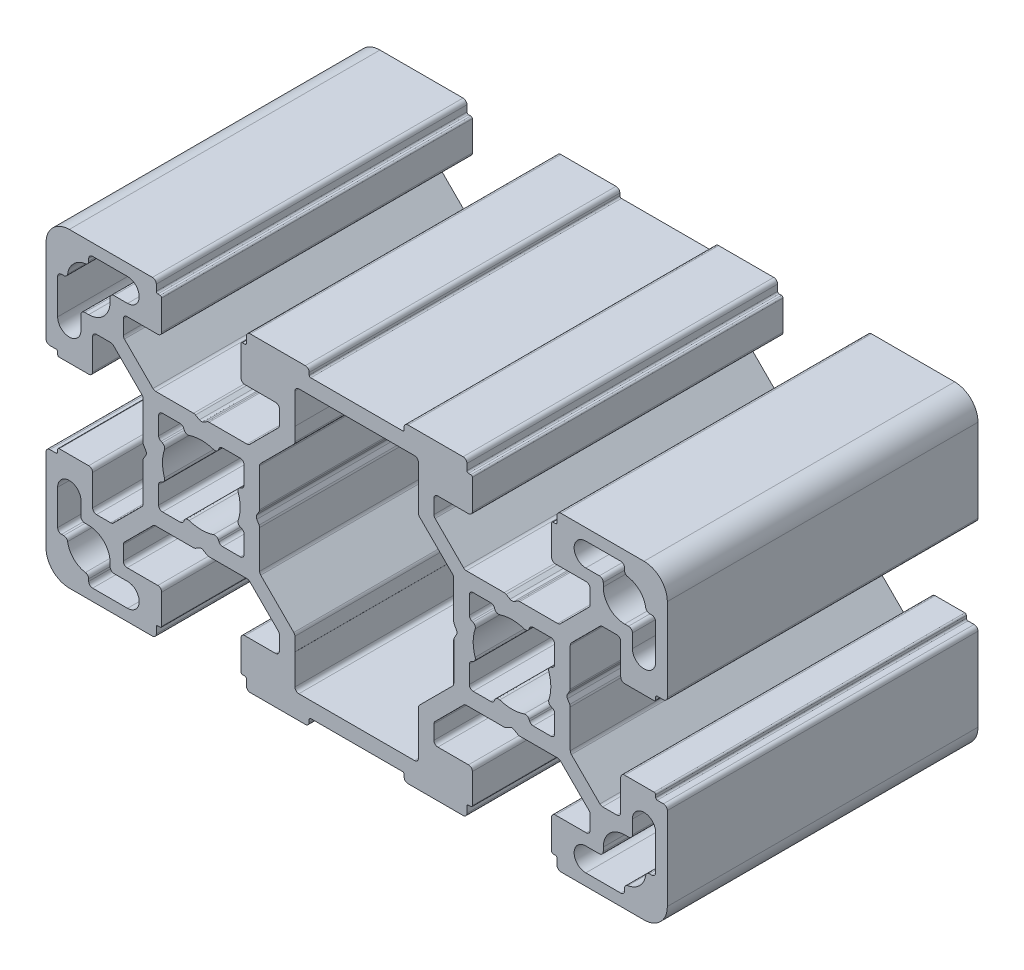
from build123d import *

# Parameters (mm, degrees)
EXTRUDE_1_DEPTH = 40


with BuildPart() as part:
    # Эскиз1 → Бобышка-Вытянуть1 (new body)
    with BuildSketch(Plane.XY):
        with BuildLine():
            Line((0.75, 7.433012702), (0.25, 7.144337567))
            ThreePointArc((0.25, 7.144337567), (0, 7.077350269), (-0.25, 7.144337567))
            Line((-0.25, 7.144337567), (-0.75, 7.433012702))
            ThreePointArc((-0.75, 7.433012702), (-0.870590477, 7.482962913), (-1, 7.5))
            Line((-1, 7.5), (-5.878679656, 7.5))
            ThreePointArc((-5.878679656, 7.5), (-6.070021373, 7.538060234), (-6.232233047, 7.646446609))
            Line((-6.232233047, 7.646446609), (-9.903553391, 11.317766953))
            ThreePointArc((-9.903553391, 11.317766953), (-10.011939766, 11.479978627), (-10.05, 11.671320344))
            Line((-10.05, 11.671320344), (-10.05, 13.5))
            ThreePointArc((-10.05, 13.5), (-9.903553391, 13.853553391), (-9.55, 14))
            Line((-9.55, 14), (-5.6, 14))
            ThreePointArc((-5.6, 14), (-5.246446609, 14.146446609), (-5.1, 14.5))
            Line((-5.1, 14.5), (-5.1, 18.3))
            ThreePointArc((-5.1, 18.3), (-5.158578644, 18.441421356), (-5.3, 18.5))
            Line((-5.3, 18.5), (-5.6, 18.5))
            ThreePointArc((-5.6, 18.5), (-5.741421356, 18.558578644), (-5.8, 18.7))
            Line((-5.8, 18.7), (-5.8, 19.5))
            ThreePointArc((-5.8, 19.5), (-5.946446609, 19.853553391), (-6.3, 20))
            Line((-6.3, 20), (-17, 20))
            ThreePointArc((-17, 20), (-19.121320344, 19.121320344), (-20, 17))
            Line((-20, 17), (-20, 6.3))
            ThreePointArc((-20, 6.3), (-19.853553391, 5.946446609), (-19.5, 5.8))
            Line((-19.5, 5.8), (-18.7, 5.8))
            ThreePointArc((-18.7, 5.8), (-18.558578644, 5.741421356), (-18.5, 5.6))
            Line((-18.5, 5.6), (-18.5, 5.3))
            ThreePointArc((-18.5, 5.3), (-18.441421356, 5.158578644), (-18.3, 5.1))
            Line((-18.3, 5.1), (-14.5, 5.1))
            ThreePointArc((-14.5, 5.1), (-14.146446609, 5.246446609), (-14, 5.6))
            Line((-14, 5.6), (-14, 9.55))
            ThreePointArc((-14, 9.55), (-13.853553391, 9.903553391), (-13.5, 10.05))
            Line((-13.5, 10.05), (-11.671320344, 10.05))
            ThreePointArc((-11.671320344, 10.05), (-11.479978627, 10.011939766), (-11.317766953, 9.903553391))
            Line((-11.317766953, 9.903553391), (-7.646446609, 6.232233047))
            ThreePointArc((-7.646446609, 6.232233047), (-7.538060234, 6.070021373), (-7.5, 5.878679656))
            Line((-7.5, 5.878679656), (-7.5, 1))
            ThreePointArc((-7.5, 1), (-7.482962913, 0.870590477), (-7.433012702, 0.75))
            Line((-7.433012702, 0.75), (-7.144337567, 0.25))
            ThreePointArc((-7.144337567, 0.25), (-7.077350269, 0), (-7.144337567, -0.25))
            Line((-7.144337567, -0.25), (-7.433012702, -0.75))
            ThreePointArc((-7.433012702, -0.75), (-7.482962913, -0.870590477), (-7.5, -1))
            Line((-7.5, -1), (-7.5, -5.878679656))
            ThreePointArc((-7.5, -5.878679656), (-7.538060234, -6.070021373), (-7.646446609, -6.232233047))
            Line((-7.646446609, -6.232233047), (-11.317766953, -9.903553391))
            ThreePointArc((-11.317766953, -9.903553391), (-11.479978627, -10.011939766), (-11.671320344, -10.05))
            Line((-11.671320344, -10.05), (-13.5, -10.05))
            ThreePointArc((-13.5, -10.05), (-13.853553391, -9.903553391), (-14, -9.55))
            Line((-14, -9.55), (-14, -5.6))
            ThreePointArc((-14, -5.6), (-14.146446609, -5.246446609), (-14.5, -5.1))
            Line((-14.5, -5.1), (-18.3, -5.1))
            ThreePointArc((-18.3, -5.1), (-18.441421356, -5.158578644), (-18.5, -5.3))
            Line((-18.5, -5.3), (-18.5, -5.6))
            ThreePointArc((-18.5, -5.6), (-18.558578644, -5.741421356), (-18.7, -5.8))
            Line((-18.7, -5.8), (-19.5, -5.8))
            ThreePointArc((-19.5, -5.8), (-19.853553391, -5.946446609), (-20, -6.3))
            Line((-20, -6.3), (-20, -17))
            ThreePointArc((-20, -17), (-19.121320344, -19.121320344), (-17, -20))
            Line((-17, -20), (-6.3, -20))
            ThreePointArc((-6.3, -20), (-5.946446609, -19.853553391), (-5.8, -19.5))
            Line((-5.8, -19.5), (-5.8, -18.7))
            ThreePointArc((-5.8, -18.7), (-5.741421356, -18.558578644), (-5.6, -18.5))
            Line((-5.6, -18.5), (-5.3, -18.5))
            ThreePointArc((-5.3, -18.5), (-5.158578644, -18.441421356), (-5.1, -18.3))
            Line((-5.1, -18.3), (-5.1, -14.5))
            ThreePointArc((-5.1, -14.5), (-5.246446609, -14.146446609), (-5.6, -14))
            Line((-5.6, -14), (-9.55, -14))
            ThreePointArc((-9.55, -14), (-9.903553391, -13.853553391), (-10.05, -13.5))
            Line((-10.05, -13.5), (-10.05, -11.671320344))
            ThreePointArc((-10.05, -11.671320344), (-10.011939766, -11.479978627), (-9.903553391, -11.317766953))
            Line((-9.903553391, -11.317766953), (-6.232233047, -7.646446609))
            ThreePointArc((-6.232233047, -7.646446609), (-6.070021373, -7.538060234), (-5.878679656, -7.5))
            Line((-5.878679656, -7.5), (-1, -7.5))
            ThreePointArc((-1, -7.5), (-0.870590477, -7.482962913), (-0.75, -7.433012702))
            Line((-0.75, -7.433012702), (-0.25, -7.144337567))
            ThreePointArc((-0.25, -7.144337567), (0, -7.077350269), (0.25, -7.144337567))
            Line((0.25, -7.144337567), (0.75, -7.433012702))
            ThreePointArc((0.75, -7.433012702), (0.870590477, -7.482962913), (1, -7.5))
            Line((1, -7.5), (5.878679656, -7.5))
            ThreePointArc((5.878679656, -7.5), (6.070021373, -7.538060234), (6.232233047, -7.646446609))
            Line((6.232233047, -7.646446609), (9.903553391, -11.317766953))
            ThreePointArc((9.903553391, -11.317766953), (10.011939766, -11.479978627), (10.05, -11.671320344))
            Line((10.05, -11.671320344), (10.05, -13.5))
            ThreePointArc((10.05, -13.5), (9.903553391, -13.853553391), (9.55, -14))
            Line((9.55, -14), (5.6, -14))
            ThreePointArc((5.6, -14), (5.246446609, -14.146446609), (5.1, -14.5))
            Line((5.1, -14.5), (5.1, -18.3))
            ThreePointArc((5.1, -18.3), (5.158578644, -18.441421356), (5.3, -18.5))
            Line((5.3, -18.5), (5.6, -18.5))
            ThreePointArc((5.6, -18.5), (5.741421356, -18.558578644), (5.8, -18.7))
            Line((5.8, -18.7), (5.8, -19.5))
            ThreePointArc((5.8, -19.5), (5.946446609, -19.853553391), (6.3, -20))
            Line((6.3, -20), (13.39, -20))
            ThreePointArc((13.39, -20), (13.743553391, -19.853553391), (13.89, -19.5))
            Line((13.89, -19.5), (13.89, -19.2))
            ThreePointArc((13.89, -19.2), (13.948578644, -19.058578644), (14.09, -19))
            Line((14.09, -19), (25.91, -19))
            ThreePointArc((25.91, -19), (26.051421356, -19.058578644), (26.11, -19.2))
            Line((26.11, -19.2), (26.11, -19.5))
            ThreePointArc((26.11, -19.5), (26.256446609, -19.853553391), (26.61, -20))
            Line((26.61, -20), (33.7, -20))
            ThreePointArc((33.7, -20), (34.053553391, -19.853553391), (34.2, -19.5))
            Line((34.2, -19.5), (34.2, -18.7))
            ThreePointArc((34.2, -18.7), (34.258578644, -18.558578644), (34.4, -18.5))
            Line((34.4, -18.5), (34.7, -18.5))
            ThreePointArc((34.7, -18.5), (34.841421356, -18.441421356), (34.9, -18.3))
            Line((34.9, -18.3), (34.9, -14.5))
            ThreePointArc((34.9, -14.5), (34.753553391, -14.146446609), (34.4, -14))
            Line((34.4, -14), (30.45, -14))
            ThreePointArc((30.45, -14), (30.096446609, -13.853553391), (29.95, -13.5))
            Line((29.95, -13.5), (29.95, -11.671320344))
            ThreePointArc((29.95, -11.671320344), (29.988060234, -11.479978627), (30.096446609, -11.317766953))
            Line((30.096446609, -11.317766953), (33.767766953, -7.646446609))
            ThreePointArc((33.767766953, -7.646446609), (33.929978627, -7.538060234), (34.121320344, -7.5))
            Line((34.121320344, -7.5), (39, -7.5))
            ThreePointArc((39, -7.5), (39.129409523, -7.482962913), (39.25, -7.433012702))
            Line((39.25, -7.433012702), (39.75, -7.144337567))
            ThreePointArc((39.75, -7.144337567), (40, -7.077350269), (40.25, -7.144337567))
            Line((40.25, -7.144337567), (40.75, -7.433012702))
            ThreePointArc((40.75, -7.433012702), (40.870590477, -7.482962913), (41, -7.5))
            Line((41, -7.5), (45.878679656, -7.5))
            ThreePointArc((45.878679656, -7.5), (46.070021373, -7.538060234), (46.232233047, -7.646446609))
            Line((46.232233047, -7.646446609), (49.903553391, -11.317766953))
            ThreePointArc((49.903553391, -11.317766953), (50.011939766, -11.479978627), (50.05, -11.671320344))
            Line((50.05, -11.671320344), (50.05, -13.5))
            ThreePointArc((50.05, -13.5), (49.903553391, -13.853553391), (49.55, -14))
            Line((49.55, -14), (45.6, -14))
            ThreePointArc((45.6, -14), (45.246446609, -14.146446609), (45.1, -14.5))
            Line((45.1, -14.5), (45.1, -18.3))
            ThreePointArc((45.1, -18.3), (45.158578644, -18.441421356), (45.3, -18.5))
            Line((45.3, -18.5), (45.6, -18.5))
            ThreePointArc((45.6, -18.5), (45.741421356, -18.558578644), (45.8, -18.7))
            Line((45.8, -18.7), (45.8, -19.5))
            ThreePointArc((45.8, -19.5), (45.946446609, -19.853553391), (46.3, -20))
            Line((46.3, -20), (57, -20))
            ThreePointArc((57, -20), (59.121320344, -19.121320344), (60, -17))
            Line((60, -17), (60, -6.3))
            ThreePointArc((60, -6.3), (59.853553391, -5.946446609), (59.5, -5.8))
            Line((59.5, -5.8), (58.7, -5.8))
            ThreePointArc((58.7, -5.8), (58.558578644, -5.741421356), (58.5, -5.6))
            Line((58.5, -5.6), (58.5, -5.3))
            ThreePointArc((58.5, -5.3), (58.441421356, -5.158578644), (58.3, -5.1))
            Line((58.3, -5.1), (54.5, -5.1))
            ThreePointArc((54.5, -5.1), (54.146446609, -5.246446609), (54, -5.6))
            Line((54, -5.6), (54, -9.55))
            ThreePointArc((54, -9.55), (53.853553391, -9.903553391), (53.5, -10.05))
            Line((53.5, -10.05), (51.671320344, -10.05))
            ThreePointArc((51.671320344, -10.05), (51.479978627, -10.011939766), (51.317766953, -9.903553391))
            Line((51.317766953, -9.903553391), (47.646446609, -6.232233047))
            ThreePointArc((47.646446609, -6.232233047), (47.538060234, -6.070021373), (47.5, -5.878679656))
            Line((47.5, -5.878679656), (47.5, -1))
            ThreePointArc((47.5, -1), (47.482962913, -0.870590477), (47.433012702, -0.75))
            Line((47.433012702, -0.75), (47.144337567, -0.25))
            ThreePointArc((47.144337567, -0.25), (47.077350269, 0), (47.144337567, 0.25))
            Line((47.144337567, 0.25), (47.433012702, 0.75))
            ThreePointArc((47.433012702, 0.75), (47.482962913, 0.870590477), (47.5, 1))
            Line((47.5, 1), (47.5, 5.878679656))
            ThreePointArc((47.5, 5.878679656), (47.538060234, 6.070021373), (47.646446609, 6.232233047))
            Line((47.646446609, 6.232233047), (51.317766953, 9.903553391))
            ThreePointArc((51.317766953, 9.903553391), (51.479978627, 10.011939766), (51.671320344, 10.05))
            Line((51.671320344, 10.05), (53.5, 10.05))
            ThreePointArc((53.5, 10.05), (53.853553391, 9.903553391), (54, 9.55))
            Line((54, 9.55), (54, 5.6))
            ThreePointArc((54, 5.6), (54.146446609, 5.246446609), (54.5, 5.1))
            Line((54.5, 5.1), (58.3, 5.1))
            ThreePointArc((58.3, 5.1), (58.441421356, 5.158578644), (58.5, 5.3))
            Line((58.5, 5.3), (58.5, 5.6))
            ThreePointArc((58.5, 5.6), (58.558578644, 5.741421356), (58.7, 5.8))
            Line((58.7, 5.8), (59.5, 5.8))
            ThreePointArc((59.5, 5.8), (59.853553391, 5.946446609), (60, 6.3))
            Line((60, 6.3), (60, 17))
            ThreePointArc((60, 17), (59.121320344, 19.121320344), (57, 20))
            Line((57, 20), (46.3, 20))
            ThreePointArc((46.3, 20), (45.946446609, 19.853553391), (45.8, 19.5))
            Line((45.8, 19.5), (45.8, 18.7))
            ThreePointArc((45.8, 18.7), (45.741421356, 18.558578644), (45.6, 18.5))
            Line((45.6, 18.5), (45.3, 18.5))
            ThreePointArc((45.3, 18.5), (45.158578644, 18.441421356), (45.1, 18.3))
            Line((45.1, 18.3), (45.1, 14.5))
            ThreePointArc((45.1, 14.5), (45.246446609, 14.146446609), (45.6, 14))
            Line((45.6, 14), (49.55, 14))
            ThreePointArc((49.55, 14), (49.903553391, 13.853553391), (50.05, 13.5))
            Line((50.05, 13.5), (50.05, 11.671320344))
            ThreePointArc((50.05, 11.671320344), (50.011939766, 11.479978627), (49.903553391, 11.317766953))
            Line((49.903553391, 11.317766953), (46.232233047, 7.646446609))
            ThreePointArc((46.232233047, 7.646446609), (46.070021373, 7.538060234), (45.878679656, 7.5))
            Line((45.878679656, 7.5), (41, 7.5))
            ThreePointArc((41, 7.5), (40.870590477, 7.482962913), (40.75, 7.433012702))
            Line((40.75, 7.433012702), (40.25, 7.144337567))
            ThreePointArc((40.25, 7.144337567), (40, 7.077350269), (39.75, 7.144337567))
            Line((39.75, 7.144337567), (39.25, 7.433012702))
            ThreePointArc((39.25, 7.433012702), (39.129409523, 7.482962913), (39, 7.5))
            Line((39, 7.5), (34.121320344, 7.5))
            ThreePointArc((34.121320344, 7.5), (33.929978627, 7.538060234), (33.767766953, 7.646446609))
            Line((33.767766953, 7.646446609), (30.096446609, 11.317766953))
            ThreePointArc((30.096446609, 11.317766953), (29.988060234, 11.479978627), (29.95, 11.671320344))
            Line((29.95, 11.671320344), (29.95, 13.5))
            ThreePointArc((29.95, 13.5), (30.096446609, 13.853553391), (30.45, 14))
            Line((30.45, 14), (34.4, 14))
            ThreePointArc((34.4, 14), (34.753553391, 14.146446609), (34.9, 14.5))
            Line((34.9, 14.5), (34.9, 18.3))
            ThreePointArc((34.9, 18.3), (34.841421356, 18.441421356), (34.7, 18.5))
            Line((34.7, 18.5), (34.4, 18.5))
            ThreePointArc((34.4, 18.5), (34.258578644, 18.558578644), (34.2, 18.7))
            Line((34.2, 18.7), (34.2, 19.5))
            ThreePointArc((34.2, 19.5), (34.053553391, 19.853553391), (33.7, 20))
            Line((33.7, 20), (26.61, 20))
            ThreePointArc((26.61, 20), (26.256446609, 19.853553391), (26.11, 19.5))
            Line((26.11, 19.5), (26.11, 19.2))
            ThreePointArc((26.11, 19.2), (26.051421356, 19.058578644), (25.91, 19))
            Line((25.91, 19), (14.09, 19))
            ThreePointArc((14.09, 19), (13.948578644, 19.058578644), (13.89, 19.2))
            Line((13.89, 19.2), (13.89, 19.5))
            ThreePointArc((13.89, 19.5), (13.743553391, 19.853553391), (13.39, 20))
            Line((13.39, 20), (6.3, 20))
            ThreePointArc((6.3, 20), (5.946446609, 19.853553391), (5.8, 19.5))
            Line((5.8, 19.5), (5.8, 18.7))
            ThreePointArc((5.8, 18.7), (5.741421356, 18.558578644), (5.6, 18.5))
            Line((5.6, 18.5), (5.3, 18.5))
            ThreePointArc((5.3, 18.5), (5.158578644, 18.441421356), (5.1, 18.3))
            Line((5.1, 18.3), (5.1, 14.5))
            ThreePointArc((5.1, 14.5), (5.246446609, 14.146446609), (5.6, 14))
            Line((5.6, 14), (9.55, 14))
            ThreePointArc((9.55, 14), (9.903553391, 13.853553391), (10.05, 13.5))
            Line((10.05, 13.5), (10.05, 11.671320344))
            ThreePointArc((10.05, 11.671320344), (10.011939766, 11.479978627), (9.903553391, 11.317766953))
            Line((9.903553391, 11.317766953), (6.232233047, 7.646446609))
            ThreePointArc((6.232233047, 7.646446609), (6.070021373, 7.538060234), (5.878679656, 7.5))
            Line((5.878679656, 7.5), (1, 7.5))
            ThreePointArc((1, 7.5), (0.870590477, 7.482962913), (0.75, 7.433012702))
        make_face()
        with BuildLine():
            ThreePointArc((-18, -14.5), (-18.353553391, -14.353553391), (-18.5, -14))
            Line((-18.5, -14), (-18.5, -9.5))
            ThreePointArc((-18.5, -9.5), (-17, -8), (-15.5, -9.5))
            Line((-15.5, -9.5), (-15.5, -11.25))
            ThreePointArc((-15.5, -11.25), (-15.353553391, -11.603553391), (-15, -11.75))
            Line((-15, -11.75), (-14.5, -11.75))
            ThreePointArc((-14.5, -11.75), (-12.555456352, -12.555456352), (-11.75, -14.5))
            Line((-11.75, -14.5), (-11.75, -15))
            ThreePointArc((-11.75, -15), (-11.603553391, -15.353553391), (-11.25, -15.5))
            Line((-11.25, -15.5), (-9.5, -15.5))
            ThreePointArc((-9.5, -15.5), (-8, -17), (-9.5, -18.5))
            Line((-9.5, -18.5), (-14, -18.5))
            ThreePointArc((-14, -18.5), (-14.353553391, -18.353553391), (-14.5, -18))
            Line((-14.5, -18), (-14.5, -17.711308145))
            ThreePointArc((-14.5, -17.711308145), (-14.620222737, -17.386086327), (-14.923076923, -17.217260738))
            ThreePointArc((-14.923076923, -17.217260738), (-16.444543648, -16.444543648), (-17.217260738, -14.923076923))
            ThreePointArc((-17.217260738, -14.923076923), (-17.386086327, -14.620222737), (-17.711308145, -14.5))
            Line((-17.711308145, -14.5), (-18, -14.5))
        make_face(mode=Mode.SUBTRACT)
        with BuildLine():
            Line((11.317766953, -9.903553391), (7.646446609, -6.232233047))
            ThreePointArc((7.646446609, -6.232233047), (7.538060234, -6.070021373), (7.5, -5.878679656))
            Line((7.5, -5.878679656), (7.5, -1))
            ThreePointArc((7.5, -1), (7.482962913, -0.870590477), (7.433012702, -0.75))
            Line((7.433012702, -0.75), (7.144337567, -0.25))
            ThreePointArc((7.144337567, -0.25), (7.077350269, 0), (7.144337567, 0.25))
            Line((7.144337567, 0.25), (7.433012702, 0.75))
            ThreePointArc((7.433012702, 0.75), (7.482962913, 0.870590477), (7.5, 1))
            Line((7.5, 1), (7.5, 5.878679656))
            ThreePointArc((7.5, 5.878679656), (7.538060234, 6.070021373), (7.646446609, 6.232233047))
            Line((7.646446609, 6.232233047), (11.317766953, 9.903553391))
            Line((11.317766953, 9.903553391), (11.903553391, 10.489339828))
            ThreePointArc((11.903553391, 10.489339828), (12.011939766, 10.651551503), (12.05, 10.842893219))
            Line((12.05, 10.842893219), (12.05, 12.585660172))
            Line((12.05, 12.585660172), (12.06499038, 12.580129564))
            Line((12.06499038, 12.580129564), (12.051701545, 16.498304216))
            ThreePointArc((12.051701545, 16.498304216), (12.197546236, 16.852953331), (12.55169867, 17))
            Line((12.55169867, 17), (27.44830133, 17))
            ThreePointArc((27.44830133, 17), (27.802453764, 16.852953331), (27.948298455, 16.498304216))
            Line((27.948298455, 16.498304216), (27.93500962, 12.580129564))
            Line((27.93500962, 12.580129564), (27.95, 12.585660172))
            Line((27.95, 12.585660172), (27.95, 10.842893219))
            ThreePointArc((27.95, 10.842893219), (27.988060234, 10.651551503), (28.096446609, 10.489339828))
            Line((28.096446609, 10.489339828), (28.682233047, 9.903553391))
            Line((28.682233047, 9.903553391), (32.353553391, 6.232233047))
            ThreePointArc((32.353553391, 6.232233047), (32.461939766, 6.070021373), (32.5, 5.878679656))
            Line((32.5, 5.878679656), (32.5, 1))
            ThreePointArc((32.5, 1), (32.517037087, 0.870590477), (32.566987298, 0.75))
            Line((32.566987298, 0.75), (32.855662433, 0.25))
            ThreePointArc((32.855662433, 0.25), (32.922649731, 0), (32.855662433, -0.25))
            Line((32.855662433, -0.25), (32.566987298, -0.75))
            ThreePointArc((32.566987298, -0.75), (32.517037087, -0.870590477), (32.5, -1))
            Line((32.5, -1), (32.5, -5.878679656))
            ThreePointArc((32.5, -5.878679656), (32.461939766, -6.070021373), (32.353553391, -6.232233047))
            Line((32.353553391, -6.232233047), (28.682233047, -9.903553391))
            Line((28.682233047, -9.903553391), (28.096446609, -10.489339828))
            ThreePointArc((28.096446609, -10.489339828), (27.988060234, -10.651551503), (27.95, -10.842893219))
            Line((27.95, -10.842893219), (27.95, -12.585660172))
            Line((27.95, -12.585660172), (27.93500962, -12.580129564))
            Line((27.93500962, -12.580129564), (27.948298455, -16.498304216))
            ThreePointArc((27.948298455, -16.498304216), (27.802453764, -16.852953331), (27.44830133, -17))
            Line((27.44830133, -17), (12.55169867, -17))
            ThreePointArc((12.55169867, -17), (12.197546236, -16.852953331), (12.051701545, -16.498304216))
            Line((12.051701545, -16.498304216), (12.06499038, -12.580129564))
            Line((12.06499038, -12.580129564), (12.05, -12.585660172))
            Line((12.05, -12.585660172), (12.05, -10.842893219))
            ThreePointArc((12.05, -10.842893219), (12.011939766, -10.651551503), (11.903553391, -10.489339828))
            Line((11.903553391, -10.489339828), (11.317766953, -9.903553391))
        make_face(mode=Mode.SUBTRACT)
        with BuildLine():
            Line((54.5, -17.711308145), (54.5, -18))
            ThreePointArc((54.5, -18), (54.353553391, -18.353553391), (54, -18.5))
            Line((54, -18.5), (49.5, -18.5))
            ThreePointArc((49.5, -18.5), (48, -17), (49.5, -15.5))
            Line((49.5, -15.5), (51.25, -15.5))
            ThreePointArc((51.25, -15.5), (51.603553391, -15.353553391), (51.75, -15))
            Line((51.75, -15), (51.75, -14.5))
            ThreePointArc((51.75, -14.5), (52.555456352, -12.555456352), (54.5, -11.75))
            Line((54.5, -11.75), (55, -11.75))
            ThreePointArc((55, -11.75), (55.353553391, -11.603553391), (55.5, -11.25))
            Line((55.5, -11.25), (55.5, -9.5))
            ThreePointArc((55.5, -9.5), (57, -8), (58.5, -9.5))
            Line((58.5, -9.5), (58.5, -14))
            ThreePointArc((58.5, -14), (58.353553391, -14.353553391), (58, -14.5))
            Line((58, -14.5), (57.711308145, -14.5))
            ThreePointArc((57.711308145, -14.5), (57.386086327, -14.620222737), (57.217260738, -14.923076923))
            ThreePointArc((57.217260738, -14.923076923), (56.444543648, -16.444543648), (54.923076923, -17.217260738))
            ThreePointArc((54.923076923, -17.217260738), (54.620222737, -17.386086327), (54.5, -17.711308145))
        make_face(mode=Mode.SUBTRACT)
        with BuildLine():
            Line((-5.020474811, 2.191496514), (-5.199374534, 2.269284327))
            ThreePointArc((-5.199374534, 2.269284327), (-5.418143078, 2.45366775), (-5.5, 2.727814365))
            Line((-5.5, 2.727814365), (-5.5, 5))
            ThreePointArc((-5.5, 5), (-5.353553391, 5.353553391), (-5, 5.5))
            Line((-5, 5.5), (-2.727814365, 5.5))
            ThreePointArc((-2.727814365, 5.5), (-2.45366775, 5.418143078), (-2.269284327, 5.199374534))
            Line((-2.269284327, 5.199374534), (-2.191496514, 5.020474811))
            ThreePointArc((-2.191496514, 5.020474811), (-1.936869058, 4.763314859), (-1.57542407, 4.745317587))
            ThreePointArc((-1.57542407, 4.745317587), (0, 5), (1.57542407, 4.745317587))
            ThreePointArc((1.57542407, 4.745317587), (1.936869058, 4.763314859), (2.191496514, 5.020474811))
            Line((2.191496514, 5.020474811), (2.269284327, 5.199374534))
            ThreePointArc((2.269284327, 5.199374534), (2.45366775, 5.418143078), (2.727814365, 5.5))
            Line((2.727814365, 5.5), (5, 5.5))
            ThreePointArc((5, 5.5), (5.353553391, 5.353553391), (5.5, 5))
            Line((5.5, 5), (5.5, 2.727814365))
            ThreePointArc((5.5, 2.727814365), (5.418143078, 2.45366775), (5.199374534, 2.269284327))
            Line((5.199374534, 2.269284327), (5.020474811, 2.191496514))
            ThreePointArc((5.020474811, 2.191496514), (4.763314859, 1.936869058), (4.745317587, 1.57542407))
            ThreePointArc((4.745317587, 1.57542407), (5, 0), (4.745317587, -1.57542407))
            ThreePointArc((4.745317587, -1.57542407), (4.763314859, -1.936869058), (5.020474811, -2.191496514))
            Line((5.020474811, -2.191496514), (5.199374534, -2.269284327))
            ThreePointArc((5.199374534, -2.269284327), (5.418143078, -2.45366775), (5.5, -2.727814365))
            Line((5.5, -2.727814365), (5.5, -5))
            ThreePointArc((5.5, -5), (5.353553391, -5.353553391), (5, -5.5))
            Line((5, -5.5), (2.727814365, -5.5))
            ThreePointArc((2.727814365, -5.5), (2.45366775, -5.418143078), (2.269284327, -5.199374534))
            Line((2.269284327, -5.199374534), (2.191496514, -5.020474811))
            ThreePointArc((2.191496514, -5.020474811), (1.936869058, -4.763314859), (1.57542407, -4.745317587))
            ThreePointArc((1.57542407, -4.745317587), (0, -5), (-1.57542407, -4.745317587))
            ThreePointArc((-1.57542407, -4.745317587), (-1.936869058, -4.763314859), (-2.191496514, -5.020474811))
            Line((-2.191496514, -5.020474811), (-2.269284327, -5.199374534))
            ThreePointArc((-2.269284327, -5.199374534), (-2.45366775, -5.418143078), (-2.727814365, -5.5))
            Line((-2.727814365, -5.5), (-5, -5.5))
            ThreePointArc((-5, -5.5), (-5.353553391, -5.353553391), (-5.5, -5))
            Line((-5.5, -5), (-5.5, -2.727814365))
            ThreePointArc((-5.5, -2.727814365), (-5.418143078, -2.45366775), (-5.199374534, -2.269284327))
            Line((-5.199374534, -2.269284327), (-5.020474811, -2.191496514))
            ThreePointArc((-5.020474811, -2.191496514), (-4.763314859, -1.936869058), (-4.745317587, -1.57542407))
            ThreePointArc((-4.745317587, -1.57542407), (-5, 0), (-4.745317587, 1.57542407))
            ThreePointArc((-4.745317587, 1.57542407), (-4.763314859, 1.936869058), (-5.020474811, 2.191496514))
        make_face(mode=Mode.SUBTRACT)
        with BuildLine():
            Line((-14.5, 17.711308145), (-14.5, 18))
            ThreePointArc((-14.5, 18), (-14.353553391, 18.353553391), (-14, 18.5))
            Line((-14, 18.5), (-9.5, 18.5))
            ThreePointArc((-9.5, 18.5), (-8, 17), (-9.5, 15.5))
            Line((-9.5, 15.5), (-11.25, 15.5))
            ThreePointArc((-11.25, 15.5), (-11.603553391, 15.353553391), (-11.75, 15))
            Line((-11.75, 15), (-11.75, 14.5))
            ThreePointArc((-11.75, 14.5), (-12.555456352, 12.555456352), (-14.5, 11.75))
            Line((-14.5, 11.75), (-15, 11.75))
            ThreePointArc((-15, 11.75), (-15.353553391, 11.603553391), (-15.5, 11.25))
            Line((-15.5, 11.25), (-15.5, 9.5))
            ThreePointArc((-15.5, 9.5), (-17, 8), (-18.5, 9.5))
            Line((-18.5, 9.5), (-18.5, 14))
            ThreePointArc((-18.5, 14), (-18.353553391, 14.353553391), (-18, 14.5))
            Line((-18, 14.5), (-17.711308145, 14.5))
            ThreePointArc((-17.711308145, 14.5), (-17.386086327, 14.620222737), (-17.217260738, 14.923076923))
            ThreePointArc((-17.217260738, 14.923076923), (-16.444543648, 16.444543648), (-14.923076923, 17.217260738))
            ThreePointArc((-14.923076923, 17.217260738), (-14.620222737, 17.386086327), (-14.5, 17.711308145))
        make_face(mode=Mode.SUBTRACT)
        with BuildLine():
            Line((45.020474811, -2.191496514), (45.199374534, -2.269284327))
            ThreePointArc((45.199374534, -2.269284327), (45.418143078, -2.45366775), (45.5, -2.727814365))
            Line((45.5, -2.727814365), (45.5, -5))
            ThreePointArc((45.5, -5), (45.353553391, -5.353553391), (45, -5.5))
            Line((45, -5.5), (42.727814365, -5.5))
            ThreePointArc((42.727814365, -5.5), (42.45366775, -5.418143078), (42.269284327, -5.199374534))
            Line((42.269284327, -5.199374534), (42.191496514, -5.020474811))
            ThreePointArc((42.191496514, -5.020474811), (41.936869058, -4.763314859), (41.57542407, -4.745317587))
            ThreePointArc((41.57542407, -4.745317587), (40, -5), (38.42457593, -4.745317587))
            ThreePointArc((38.42457593, -4.745317587), (38.063130942, -4.763314859), (37.808503486, -5.020474811))
            Line((37.808503486, -5.020474811), (37.730715673, -5.199374534))
            ThreePointArc((37.730715673, -5.199374534), (37.54633225, -5.418143078), (37.272185635, -5.5))
            Line((37.272185635, -5.5), (35, -5.5))
            ThreePointArc((35, -5.5), (34.646446609, -5.353553391), (34.5, -5))
            Line((34.5, -5), (34.5, -2.727814365))
            ThreePointArc((34.5, -2.727814365), (34.581856922, -2.45366775), (34.800625466, -2.269284327))
            Line((34.800625466, -2.269284327), (34.979525189, -2.191496514))
            ThreePointArc((34.979525189, -2.191496514), (35.236685141, -1.936869058), (35.254682413, -1.57542407))
            ThreePointArc((35.254682413, -1.57542407), (35, 0), (35.254682413, 1.57542407))
            ThreePointArc((35.254682413, 1.57542407), (35.236685141, 1.936869058), (34.979525189, 2.191496514))
            Line((34.979525189, 2.191496514), (34.800625466, 2.269284327))
            ThreePointArc((34.800625466, 2.269284327), (34.581856922, 2.45366775), (34.5, 2.727814365))
            Line((34.5, 2.727814365), (34.5, 5))
            ThreePointArc((34.5, 5), (34.646446609, 5.353553391), (35, 5.5))
            Line((35, 5.5), (37.272185635, 5.5))
            ThreePointArc((37.272185635, 5.5), (37.54633225, 5.418143078), (37.730715673, 5.199374534))
            Line((37.730715673, 5.199374534), (37.808503486, 5.020474811))
            ThreePointArc((37.808503486, 5.020474811), (38.063130942, 4.763314859), (38.42457593, 4.745317587))
            ThreePointArc((38.42457593, 4.745317587), (40, 5), (41.57542407, 4.745317587))
            ThreePointArc((41.57542407, 4.745317587), (41.936869058, 4.763314859), (42.191496514, 5.020474811))
            Line((42.191496514, 5.020474811), (42.269284327, 5.199374534))
            ThreePointArc((42.269284327, 5.199374534), (42.45366775, 5.418143078), (42.727814365, 5.5))
            Line((42.727814365, 5.5), (45, 5.5))
            ThreePointArc((45, 5.5), (45.353553391, 5.353553391), (45.5, 5))
            Line((45.5, 5), (45.5, 2.727814365))
            ThreePointArc((45.5, 2.727814365), (45.418143078, 2.45366775), (45.199374534, 2.269284327))
            Line((45.199374534, 2.269284327), (45.020474811, 2.191496514))
            ThreePointArc((45.020474811, 2.191496514), (44.763314859, 1.936869058), (44.745317587, 1.57542407))
            ThreePointArc((44.745317587, 1.57542407), (45, 0), (44.745317587, -1.57542407))
            ThreePointArc((44.745317587, -1.57542407), (44.763314859, -1.936869058), (45.020474811, -2.191496514))
        make_face(mode=Mode.SUBTRACT)
        with BuildLine():
            ThreePointArc((58, 14.5), (58.353553391, 14.353553391), (58.5, 14))
            Line((58.5, 14), (58.5, 9.5))
            ThreePointArc((58.5, 9.5), (57, 8), (55.5, 9.5))
            Line((55.5, 9.5), (55.5, 11.25))
            ThreePointArc((55.5, 11.25), (55.353553391, 11.603553391), (55, 11.75))
            Line((55, 11.75), (54.5, 11.75))
            ThreePointArc((54.5, 11.75), (52.555456352, 12.555456352), (51.75, 14.5))
            Line((51.75, 14.5), (51.75, 15))
            ThreePointArc((51.75, 15), (51.603553391, 15.353553391), (51.25, 15.5))
            Line((51.25, 15.5), (49.5, 15.5))
            ThreePointArc((49.5, 15.5), (48, 17), (49.5, 18.5))
            Line((49.5, 18.5), (54, 18.5))
            ThreePointArc((54, 18.5), (54.353553391, 18.353553391), (54.5, 18))
            Line((54.5, 18), (54.5, 17.711308145))
            ThreePointArc((54.5, 17.711308145), (54.620222737, 17.386086327), (54.923076923, 17.217260738))
            ThreePointArc((54.923076923, 17.217260738), (56.444543648, 16.444543648), (57.217260738, 14.923076923))
            ThreePointArc((57.217260738, 14.923076923), (57.386086327, 14.620222737), (57.711308145, 14.5))
            Line((57.711308145, 14.5), (58, 14.5))
        make_face(mode=Mode.SUBTRACT)
    extrude(amount=EXTRUDE_1_DEPTH)


solid = part.part
